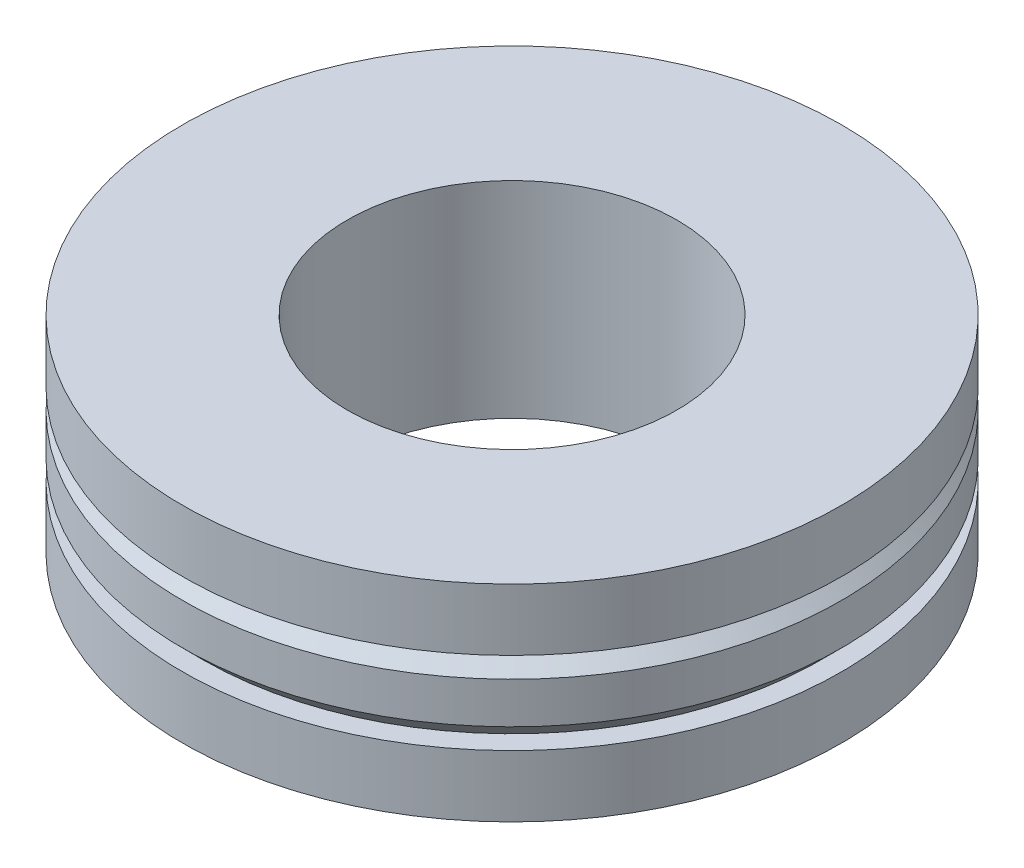
from build123d import *


with BuildPart() as part:
    # 草图1 → 旋转1 (revolve)
    with BuildSketch(Plane.XY):
        Polygon((-112, 5), (-116, 5), (-116, 0), (-112, 0), (-112, 1.5), (-112.5, 1.5), (-112, 2), (-112, 3), (-112.5, 3.5), (-112, 3.5), align=None)
    revolve(axis=Axis((-120, 5, 0), (0, -1, 0)))


solid = part.part
